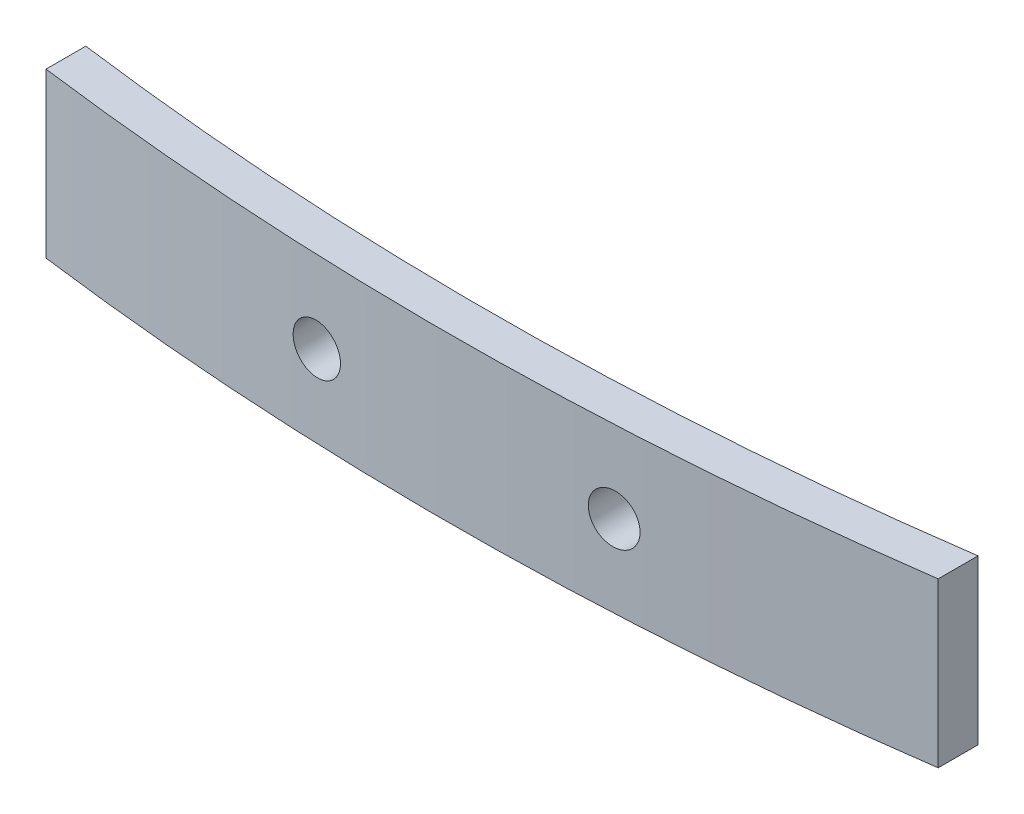
from build123d import *

# Parameters (mm, degrees)
BOSS_EXTRUDE1_DEPTH     = 8.3
SKETCH2_R               = 1.25
CUT_EXTRUDE1_DEPTH      = 3.700074126
CUT_EXTRUDE1_DEPTH_BACK = 1.960467608


with BuildPart() as part:
    # Sketch1 → Boss-Extrude1 (new body)
    with BuildSketch(Plane(origin=(0, 0, 0), x_dir=(1, 0, 0), z_dir=(0, 1, 0))):
        with BuildLine():
            Line((22.5, 0.960467608), (22.5, -1.059592066))
            ThreePointArc((22.5, -1.059592066), (0.00793889, -2.697795715), (-22.5, -1.2945099))
            Line((-22.5, -1.2945099), (-22.5, 0.722652417))
            ThreePointArc((-22.5, 0.722652417), (0.008135008, -0.697767096), (22.5, 0.960467608))
        make_face()
    extrude(amount=BOSS_EXTRUDE1_DEPTH)

    # Sketch2 → Cut-Extrude1 (cut, two sides)
    with BuildSketch(Plane.XY) as cut_extrude1_sk:
        with Locations((7.5, 4.15)):
            Circle(SKETCH2_R)
        with Locations((-7.5, 4.15)):
            Circle(SKETCH2_R)
    extrude(amount=CUT_EXTRUDE1_DEPTH, mode=Mode.SUBTRACT)
    extrude(cut_extrude1_sk.sketch, amount=-CUT_EXTRUDE1_DEPTH_BACK, mode=Mode.SUBTRACT)


solid = part.part
